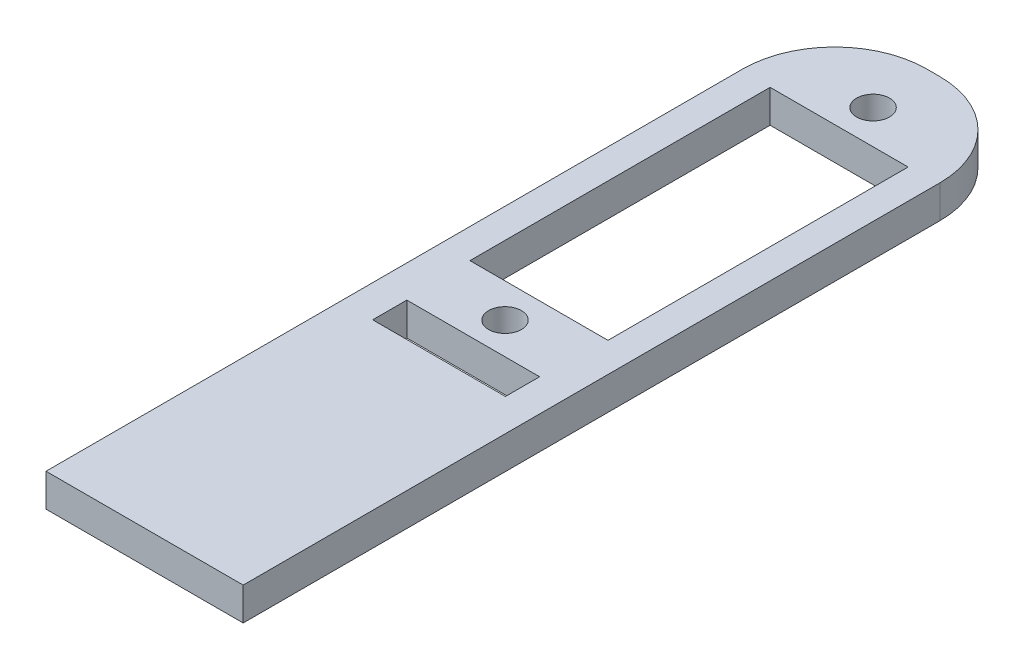
from build123d import *

# Parameters (mm, degrees)
SKETCH1_W           = 19.05
SKETCH1_H           = 76.2
SKETCH1_R           = 1.5875
SKETCH1_W_2         = 13.335
SKETCH1_H_2         = 29
SKETCH1_W_3         = 12.827
SKETCH1_H_3         = 3.302
BOSS_EXTRUDE1_DEPTH = 3.175
FILLET1_R           = 8.89
FILLET2_R           = 8.89


with BuildPart() as part:
    # Sketch1 → Boss-Extrude1 (new body)
    with BuildSketch(Plane(origin=(0, 0, 0), x_dir=(1, 0, 0), z_dir=(0, 1, 0))):
        Rectangle(SKETCH1_W, SKETCH1_H)
        with Locations((0, 32.28)):
            Circle(SKETCH1_R, mode=Mode.SUBTRACT)
        with Locations((0, -3.28)):
            Circle(SKETCH1_R, mode=Mode.SUBTRACT)
        with Locations((0, 14.5)):
            Rectangle(SKETCH1_W_2, SKETCH1_H_2, mode=Mode.SUBTRACT)
        with Locations((0, -8.001)):
            Rectangle(SKETCH1_W_3, SKETCH1_H_3, mode=Mode.SUBTRACT)
    extrude(amount=BOSS_EXTRUDE1_DEPTH)

    # Fillet1
    fillet1_edges = [part.edges().sort_by_distance(p)[0] for p in [
        (9.525, 1.5875, -38.1),
    ]]
    fillet(fillet1_edges, radius=FILLET1_R)

    # Fillet2
    fillet2_edges = [part.edges().sort_by_distance(p)[0] for p in [
        (-9.525, 1.5875, -38.1),
    ]]
    fillet(fillet2_edges, radius=FILLET2_R)


solid = part.part
